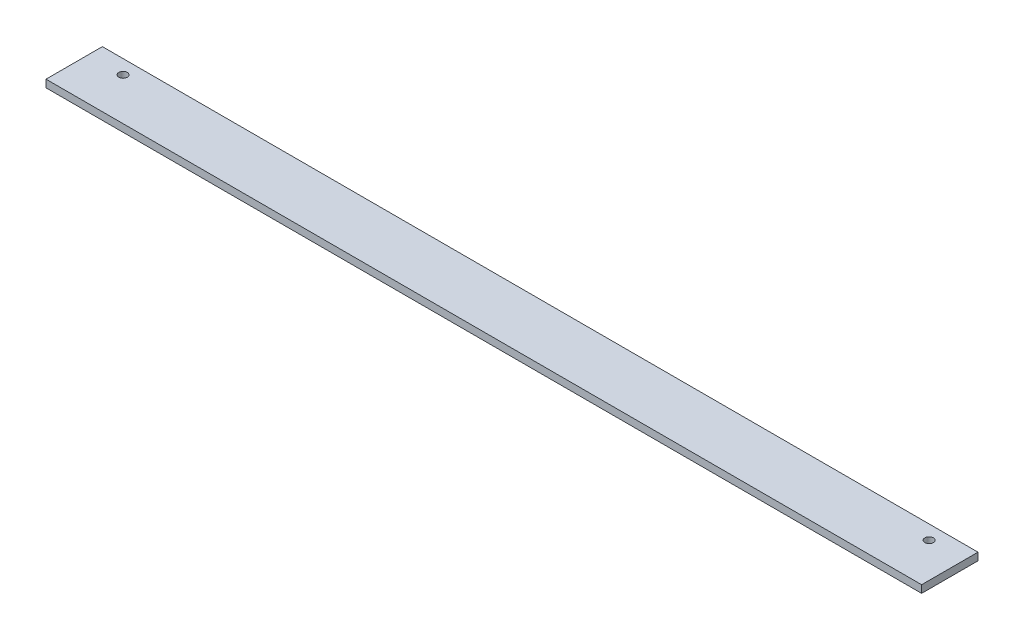
from build123d import *

# Parameters (mm, degrees)
SKETCH_1_W          = 30
SKETCH_1_H          = 4
EXTRUDE_1_DEPTH     = 466
SKETCH_2_R          = 2.25
CUT_EXTRUDE_1_DEPTH = 5


with BuildPart() as part:
    # Эскиз1 → Бобышка-Вытянуть1 (new body)
    with BuildSketch(Plane(origin=(0, 0, 0), x_dir=(0, 0, -1), z_dir=(1, 0, 0))):
        Rectangle(SKETCH_1_W, SKETCH_1_H)
    extrude(amount=EXTRUDE_1_DEPTH)

    # Эскиз2 → Вырез-Вытянуть1 (cut, through all)
    with BuildSketch(Plane(origin=(0, 2, 0), x_dir=(1, 0, 0), z_dir=(0, 1, 0))):
        with Locations((18.5, 7.5)):
            Circle(SKETCH_2_R)
        with Locations((447.5, 7.5)):
            Circle(SKETCH_2_R)
    extrude(amount=-CUT_EXTRUDE_1_DEPTH, mode=Mode.SUBTRACT)


solid = part.part
